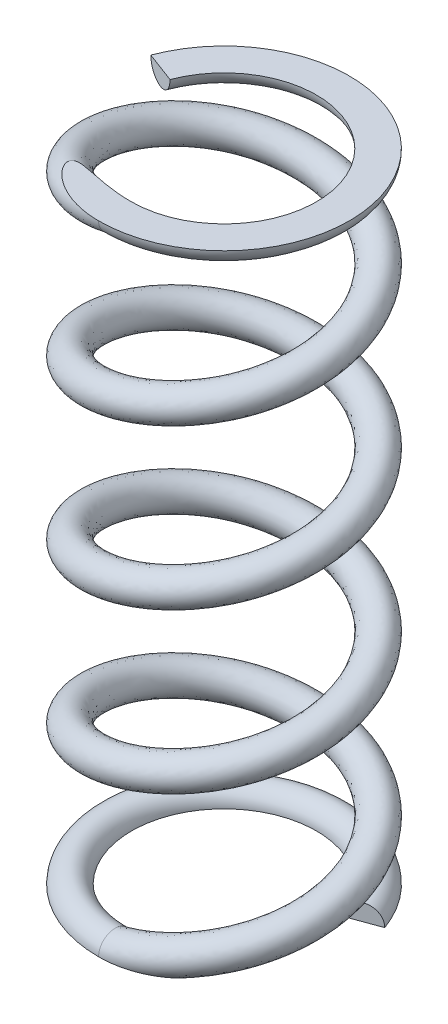
from build123d import *

# Parameters (mm, degrees)
SWEEP7_PITCH            = 31.75
SWEEP7_HEIGHT           = 127
SWEEP7_RADIUS           = 21.717
SKETCH5_R               = 3.28
SKETCH5_5_R             = 3.28
SKETCH7_R               = 3.28
CUT_W                   = 103.551068572
CUT_H                   = 23.082513744
CUT_H_2                 = 30.073571719
CUT_EXTRUDE3_DEPTH      = 25.9970001
CUT_EXTRUDE3_DEPTH_BACK = 25.9970001


with BuildPart() as part:
    # Sweep7: sweep along a helix
    with BuildLine() as sweep7_path:
        Helix(SWEEP7_PITCH, SWEEP7_HEIGHT, SWEEP7_RADIUS, center=(0, 0, 0), direction=(0, 1, 0))
    # Sketch5 → Sweep7 (sweep)
    with BuildSketch(Plane(origin=(0, 0, 0), x_dir=(0, 0, -1), z_dir=(1, 0, 0))):
        with Locations((-21.717, 0)):
            Circle(SKETCH5_R)
    sweep(path=sweep7_path.line, is_frenet=True)

    # Sweep8: sweep along a path in Sketch3
    with BuildLine(Plane(origin=(0, 0, 0), x_dir=(1, 0, 0), z_dir=(0, 1, 0))) as sweep8_path:
        ThreePointArc((23.229201586, 8.454737943), (-20.249438535, 14.178809507), (0, -24.72))
    # Sketch5_5 → Sweep8 (sweep)
    with BuildSketch(Plane(origin=(0, 0, 0), x_dir=(0, 0, -1), z_dir=(1, 0, 0))):
        with Locations((-21.717, 0)):
            Circle(SKETCH5_5_R)
    sweep(path=sweep8_path.line)

    # Sweep9: sweep along a path in Sketch6
    with BuildLine(Plane(origin=(0, 127, 0), x_dir=(1, 0, 0), z_dir=(0, 1, 0))) as sweep9_path:
        ThreePointArc((0, -21.717), (17.858904221, 12.356683578), (-20.322956992, 7.655423443))
    # Sketch7 → Sweep9 (sweep)
    with BuildSketch(Plane(origin=(0, 0, 0), x_dir=(0, 0, -1), z_dir=(1, 0, 0))):
        with Locations((-21.717, 127)):
            Circle(SKETCH7_R)
    sweep(path=sweep9_path.line)

    # Cut → Cut-Extrude3 (cut, two sides)
    with BuildSketch(Plane.XY) as cut_extrude3_sk:
        with Locations((3.208570768, 138.541256872)):
            Rectangle(CUT_W, CUT_H)
        with Locations((3.208570768, -15.03678586)):
            Rectangle(CUT_W, CUT_H_2)
    extrude(amount=CUT_EXTRUDE3_DEPTH, mode=Mode.SUBTRACT)
    extrude(cut_extrude3_sk.sketch, amount=-CUT_EXTRUDE3_DEPTH_BACK, mode=Mode.SUBTRACT)


solid = part.part
